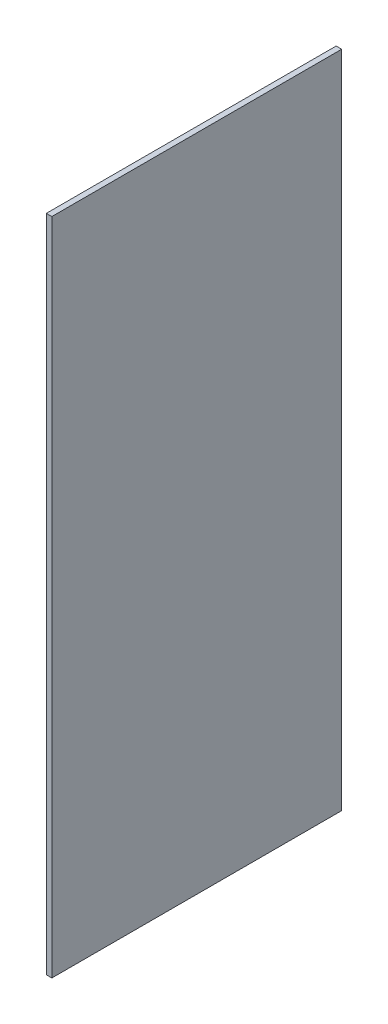
from build123d import *

# Parameters (mm, degrees)
SKETCH1_W           = 63.5
SKETCH1_H           = 144.4625
BOSS_EXTRUDE1_DEPTH = 1.21412


with BuildPart() as part:
    # Sketch1 → Boss-Extrude1 (new body)
    with BuildSketch(Plane(origin=(0, 0, 0), x_dir=(0, 0, -1), z_dir=(1, 0, 0))):
        Rectangle(SKETCH1_W, SKETCH1_H)
    extrude(amount=BOSS_EXTRUDE1_DEPTH)


solid = part.part
